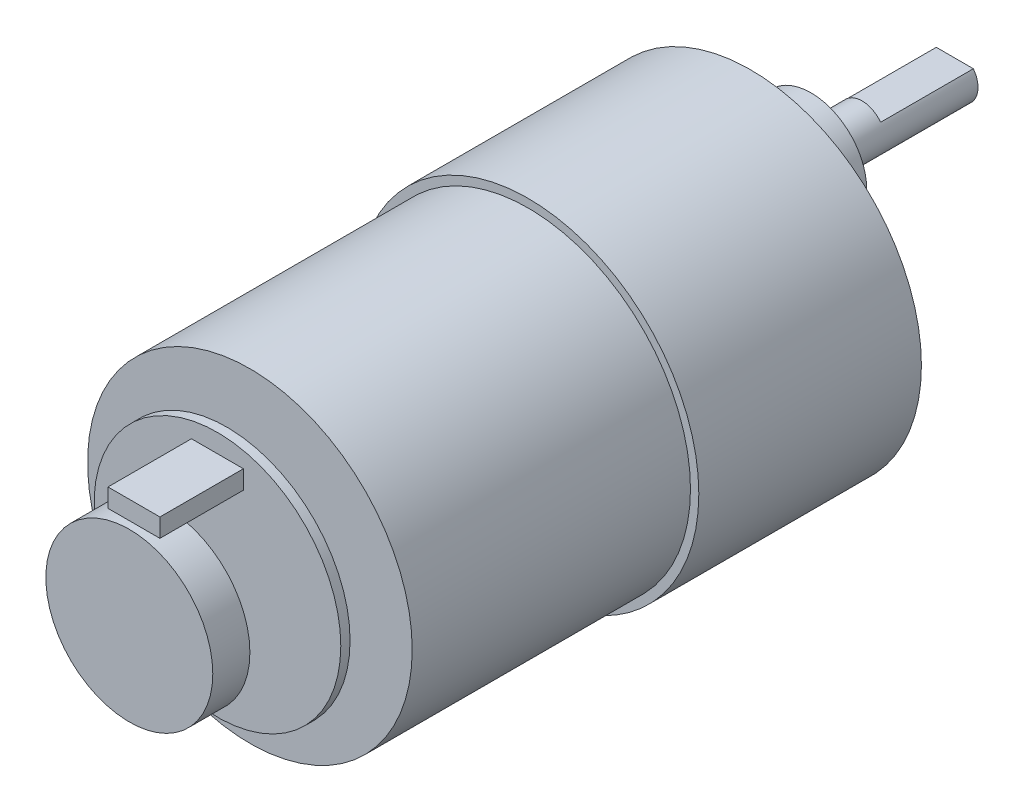
from build123d import *

# Parameters (mm, degrees)
ESBO_O1_R                 = 18.4
RESSALTO_EXTRUS_O1_DEPTH  = 24
ESBO_O2_R                 = 17.5
RESSALTO_EXTRUS_O2_DEPTH  = 30
ESBO_O3_R                 = 6
RESSALTO_EXTRUS_O3_DEPTH  = 6.5
ESBO_O4_R                 = 2.5
RESSALTO_EXTRUS_O4_DEPTH  = 15.5
ESBO_O5_R                 = 1.5
CORTE_EXTRUS_O1_DEPTH     = 10
ESBO_O6_R                 = 1
RESSALTO_EXTRUS_O5_DEPTH  = 2.5
ESBO_O8_R                 = 13.3
RESSALTO_EXTRUS_O7_DEPTH  = 1
ESBO_O9_R                 = 1
RESSALTO_EXTRUS_O8_DEPTH  = 5.5
ESBO_O10_R                = 9
RESSALTO_EXTRUS_O9_DEPTH  = 4
ESBO_O11_W                = 5.6
ESBO_O11_H                = 2
RESSALTO_EXTRUS_O10_DEPTH = 9
ESBO_O12_OUTSIDE_W        = 59.42
ESBO_O12_OUTSIDE_H        = 59.42
CORTE_EXTRUS_O2_DEPTH     = 10


with BuildPart() as part:
    # Esboço1 → Ressalto-extrusão1 (new body)
    with BuildSketch(Plane.XY):
        Circle(ESBO_O1_R)
    extrude(amount=RESSALTO_EXTRUS_O1_DEPTH)

    # Esboço2 → Ressalto-extrusão2 (add)
    with BuildSketch(Plane.XY.offset(24)):
        Circle(ESBO_O2_R)
    extrude(amount=RESSALTO_EXTRUS_O2_DEPTH)

    # Esboço3 → Ressalto-extrusão3 (add)
    with BuildSketch(Plane(origin=(0, 0, 0), x_dir=(-1, 0, 0), z_dir=(0, 0, -1))):
        with Locations((0, 7)):
            Circle(ESBO_O3_R)
    extrude(amount=RESSALTO_EXTRUS_O3_DEPTH)

    # Esboço4 → Ressalto-extrusão4 (add)
    with BuildSketch(Plane(origin=(0, 0, -6.5), x_dir=(-1, 0, 0), z_dir=(0, 0, -1))):
        with Locations((0, 7)):
            Circle(ESBO_O4_R)
    extrude(amount=RESSALTO_EXTRUS_O4_DEPTH)

    # Esboço5 → Corte-extrusão1 (cut)
    with BuildSketch(Plane(origin=(0, 0, 0), x_dir=(-1, 0, 0), z_dir=(0, 0, -1))):
        with Locations((7.485925154, 12.966002708)):
            Circle(ESBO_O5_R)
        with Locations((14.971850307, 0)):
            Circle(ESBO_O5_R)
        with Locations((7.485925154, -12.966002708)):
            Circle(ESBO_O5_R)
        with Locations((-7.485925154, -12.966002708)):
            Circle(ESBO_O5_R)
        with Locations((-14.971850307, 0)):
            Circle(ESBO_O5_R)
        with Locations((-7.485925154, 12.966002708)):
            Circle(ESBO_O5_R)
    extrude(amount=-CORTE_EXTRUS_O1_DEPTH, mode=Mode.SUBTRACT)

    # Esboço6 → Ressalto-extrusão5 (add)
    with BuildSketch(Plane.XY.offset(54)):
        Circle(ESBO_O6_R)
    extrude(amount=RESSALTO_EXTRUS_O5_DEPTH)

    # Esboço8 → Ressalto-extrusão7 (add)
    with BuildSketch(Plane.XY.offset(56.5)):
        Circle(ESBO_O8_R)
    extrude(amount=RESSALTO_EXTRUS_O7_DEPTH)

    # Esboço9 → Ressalto-extrusão8 (add)
    with BuildSketch(Plane.XY.offset(57.5)):
        Circle(ESBO_O9_R)
    extrude(amount=RESSALTO_EXTRUS_O8_DEPTH)

    # Esboço10 → Ressalto-extrusão9 (add)
    with BuildSketch(Plane.XY.offset(63)):
        Circle(ESBO_O10_R)
    extrude(amount=RESSALTO_EXTRUS_O9_DEPTH)

    # Esboço11 → Ressalto-extrusão10 (add)
    with BuildSketch(Plane.XY.offset(57.5)):
        with Locations((0, 10.3)):
            Rectangle(ESBO_O11_W, ESBO_O11_H)
    extrude(amount=RESSALTO_EXTRUS_O10_DEPTH)

    # Esboço12 outside → Corte-extrusão2 (cut)
    with BuildSketch(Plane(origin=(0, 0, -22), x_dir=(-1, 0, 0), z_dir=(0, 0, -1))):
        Rectangle(ESBO_O12_OUTSIDE_W, ESBO_O12_OUTSIDE_H)
        with BuildLine():
            Line((2, 8.5), (-2, 8.5))
            ThreePointArc((-2, 8.5), (0, 4.5), (2, 8.5))
        make_face(mode=Mode.SUBTRACT)
    extrude(amount=-CORTE_EXTRUS_O2_DEPTH, mode=Mode.SUBTRACT)


solid = part.part
